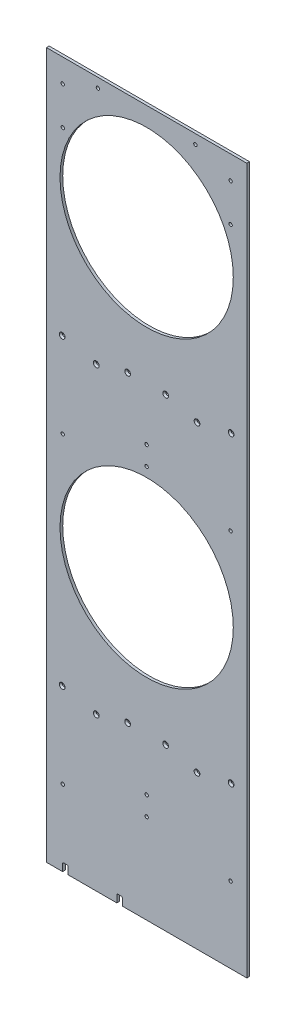
from build123d import *

# Parameters (mm, degrees)
SKETCH1_W                                     = 469.9
SKETCH1_H                                     = 2413
SKETCH1_R                                     = 203.2
BOSS_EXTRUDE1_DEPTH                           = 6.35
CSK_FOR_1_4_FLAT_HEAD_SOCKET_CAP_SCR_2_COUNT  = 2
CSK_FOR_1_4_FLAT_HEAD_SOCKET_CAP_SCR_2_PITCH  = 76.2
CSK_FOR_1_4_FLAT_HEAD_SOCKET_CAP_SCR_3_COUNT  = 2
CSK_FOR_1_4_FLAT_HEAD_SOCKET_CAP_SCR_3_PITCH  = 89.142542345
CSK_FOR_1_4_FLAT_HEAD_SOCKET_CAP_SCR_4_COUNT  = 2
CSK_FOR_1_4_FLAT_HEAD_SOCKET_CAP_SCR_4_PITCH  = 163.936718394
CSK_FOR_1_4_FLAT_HEAD_SOCKET_CAP_SCR_5_COUNT  = 2
CSK_FOR_1_4_FLAT_HEAD_SOCKET_CAP_SCR_5_PITCH  = 711.2
CSK_FOR_1_4_FLAT_HEAD_SOCKET_CAP_SCR_6_COUNT  = 2
CSK_FOR_1_4_FLAT_HEAD_SOCKET_CAP_SCR_6_PITCH  = 695.384275934
CSK_FOR_1_4_FLAT_HEAD_SOCKET_CAP_SCR_7_COUNT  = 2
CSK_FOR_1_4_FLAT_HEAD_SOCKET_CAP_SCR_7_PITCH  = 716.764837904
CSK_FOR_1_4_FLAT_HEAD_SOCKET_CAP_SCR_8_COUNT  = 2
CSK_FOR_1_4_FLAT_HEAD_SOCKET_CAP_SCR_8_PITCH  = 710.371803251
CSK_FOR_1_4_FLAT_HEAD_SOCKET_CAP_SCR_9_COUNT  = 2
CSK_FOR_1_4_FLAT_HEAD_SOCKET_CAP_SCR_9_PITCH  = 1422.4
CSK_FOR_1_4_FLAT_HEAD_SOCKET_CAP_SCR_10_COUNT = 2
CSK_FOR_1_4_FLAT_HEAD_SOCKET_CAP_SCR_10_PITCH = 1404.60778242
CSK_FOR_1_4_FLAT_HEAD_SOCKET_CAP_SCR_11_COUNT = 2
CSK_FOR_1_4_FLAT_HEAD_SOCKET_CAP_SCR_11_PITCH = 1425.190567207
CSK_FOR_1_4_FLAT_HEAD_SOCKET_CAP_SCR_12_COUNT = 2
CSK_FOR_1_4_FLAT_HEAD_SOCKET_CAP_SCR_12_PITCH = 1412.087755797
CSK_FOR_1_4_FLAT_HEAD_SOCKET_CAP_SCR_13_COUNT = 2
CSK_FOR_1_4_FLAT_HEAD_SOCKET_CAP_SCR_13_PITCH = 153.55813077
CSK_FOR_1_4_FLAT_HEAD_SOCKET_CAP_SCR_14_COUNT = 2
CSK_FOR_1_4_FLAT_HEAD_SOCKET_CAP_SCR_14_PITCH = 242.697219812
CSK_FOR_1_4_FLAT_HEAD_SOCKET_CAP_SCR_15_COUNT = 2
CSK_FOR_1_4_FLAT_HEAD_SOCKET_CAP_SCR_15_PITCH = 749.86024568
CSK_FOR_1_4_FLAT_HEAD_SOCKET_CAP_SCR_16_COUNT = 2
CSK_FOR_1_4_FLAT_HEAD_SOCKET_CAP_SCR_16_PITCH = 1441.280581843
CSK_FOR_1_4_FLAT_HEAD_SOCKET_CAP_SCR_17_COUNT = 2
CSK_FOR_1_4_FLAT_HEAD_SOCKET_CAP_SCR_17_PITCH = 1428.974413563
CSK_FOR_1_4_FLAT_HEAD_SOCKET_CAP_SCR_18_COUNT = 2
CSK_FOR_1_4_FLAT_HEAD_SOCKET_CAP_SCR_18_PITCH = 725.925992834
F_5_16_0_3125_DIAMETER_HOLE1_D                = 7.9375
SKETCH6_W                                     = 469.9
SKETCH6_H                                     = 758.19
CUT_EXTRUDE1_DEPTH                            = 7.35
SKETCH8_W                                     = 13.208
SKETCH8_H                                     = 19.05
CUT_EXTRUDE2_DEPTH                            = 7.35
FILLET1_R                                     = 3.175


with BuildPart() as part:
    # Sketch1 → Boss-Extrude1 (new body)
    with BuildSketch(Plane.XY):
        with Locations((0, 1206.5)):
            Rectangle(SKETCH1_W, SKETCH1_H)
        with Locations((0, 695.96)):
            Circle(SKETCH1_R, mode=Mode.SUBTRACT)
        with Locations((0, 1407.16)):
            Circle(SKETCH1_R, mode=Mode.SUBTRACT)
        with Locations((0, 2118.36)):
            Circle(SKETCH1_R, mode=Mode.SUBTRACT)
    extrude(amount=BOSS_EXTRUDE1_DEPTH)

    # Sketch3 → CSK for 1/4 Flat Head Socket Cap Screw1 (revolve, cut)
    with BuildSketch(Plane(origin=(44.571271172, 378.545152647, 6.35), x_dir=(0, -1, 0), z_dir=(1, 0, 0))):
        Polygon((0, 0), (0, 6.35), (3.3782, 6.35), (3.3782, 3.871564875), (6.7437, 0), align=None)
    csk_for_1_4_flat_head_socket_cap_screw1 = revolve(axis=Axis((44.571271172, 378.545152647, 12.7), (0, 0, -1)), mode=Mode.SUBTRACT)

    # CSK for 1_4 Flat Head Socket Cap Scr 2: CSK for 1/4 Flat Head Socket Cap Screw1 ×2
    with Locations(*[Vector(0.965925826, -0.258819045, 0) * (i * CSK_FOR_1_4_FLAT_HEAD_SOCKET_CAP_SCR_2_PITCH) for i in range(1, CSK_FOR_1_4_FLAT_HEAD_SOCKET_CAP_SCR_2_COUNT)]):
        add(csk_for_1_4_flat_head_socket_cap_screw1, mode=Mode.SUBTRACT)

    # CSK for 1_4 Flat Head Socket Cap Scr 3: CSK for 1/4 Flat Head Socket Cap Screw1 ×2
    with Locations(*[(-i * CSK_FOR_1_4_FLAT_HEAD_SOCKET_CAP_SCR_3_PITCH, 0, 0) for i in range(1, CSK_FOR_1_4_FLAT_HEAD_SOCKET_CAP_SCR_3_COUNT)]):
        add(csk_for_1_4_flat_head_socket_cap_screw1, mode=Mode.SUBTRACT)

    # CSK for 1_4 Flat Head Socket Cap Scr 4: CSK for 1/4 Flat Head Socket Cap Screw1 ×2
    with Locations(*[Vector(-0.99273727, -0.120302586, 0) * (i * CSK_FOR_1_4_FLAT_HEAD_SOCKET_CAP_SCR_4_PITCH) for i in range(1, CSK_FOR_1_4_FLAT_HEAD_SOCKET_CAP_SCR_4_COUNT)]):
        add(csk_for_1_4_flat_head_socket_cap_screw1, mode=Mode.SUBTRACT)

    # CSK for 1_4 Flat Head Socket Cap Scr 5: CSK for 1/4 Flat Head Socket Cap Screw1 ×2
    with Locations(*[(0, i * CSK_FOR_1_4_FLAT_HEAD_SOCKET_CAP_SCR_5_PITCH, 0) for i in range(1, CSK_FOR_1_4_FLAT_HEAD_SOCKET_CAP_SCR_5_COUNT)]):
        add(csk_for_1_4_flat_head_socket_cap_screw1, mode=Mode.SUBTRACT)

    # CSK for 1_4 Flat Head Socket Cap Scr 6: CSK for 1/4 Flat Head Socket Cap Screw1 ×2
    with Locations(*[Vector(0.105845862, 0.994382549, 0) * (i * CSK_FOR_1_4_FLAT_HEAD_SOCKET_CAP_SCR_6_PITCH) for i in range(1, CSK_FOR_1_4_FLAT_HEAD_SOCKET_CAP_SCR_6_COUNT)]):
        add(csk_for_1_4_flat_head_socket_cap_screw1, mode=Mode.SUBTRACT)

    # CSK for 1_4 Flat Head Socket Cap Scr 7: CSK for 1/4 Flat Head Socket Cap Screw1 ×2
    with Locations(*[Vector(-0.124367907, 0.992236173, 0) * (i * CSK_FOR_1_4_FLAT_HEAD_SOCKET_CAP_SCR_7_PITCH) for i in range(1, CSK_FOR_1_4_FLAT_HEAD_SOCKET_CAP_SCR_7_COUNT)]):
        add(csk_for_1_4_flat_head_socket_cap_screw1, mode=Mode.SUBTRACT)

    # CSK for 1_4 Flat Head Socket Cap Scr 8: CSK for 1/4 Flat Head Socket Cap Screw1 ×2
    with Locations(*[Vector(-0.229099874, 0.973402922, 0) * (i * CSK_FOR_1_4_FLAT_HEAD_SOCKET_CAP_SCR_8_PITCH) for i in range(1, CSK_FOR_1_4_FLAT_HEAD_SOCKET_CAP_SCR_8_COUNT)]):
        add(csk_for_1_4_flat_head_socket_cap_screw1, mode=Mode.SUBTRACT)

    # CSK for 1_4 Flat Head Socket Cap Scr 9: CSK for 1/4 Flat Head Socket Cap Screw1 ×2
    with Locations(*[(0, i * CSK_FOR_1_4_FLAT_HEAD_SOCKET_CAP_SCR_9_PITCH, 0) for i in range(1, CSK_FOR_1_4_FLAT_HEAD_SOCKET_CAP_SCR_9_COUNT)]):
        add(csk_for_1_4_flat_head_socket_cap_screw1, mode=Mode.SUBTRACT)

    # CSK for 1_4 Flat Head Socket Cap Scr 10: CSK for 1/4 Flat Head Socket Cap Screw1 ×2
    with Locations(*[Vector(0.052401495, 0.998626098, 0) * (i * CSK_FOR_1_4_FLAT_HEAD_SOCKET_CAP_SCR_10_PITCH) for i in range(1, CSK_FOR_1_4_FLAT_HEAD_SOCKET_CAP_SCR_10_COUNT)]):
        add(csk_for_1_4_flat_head_socket_cap_screw1, mode=Mode.SUBTRACT)

    # CSK for 1_4 Flat Head Socket Cap Scr 11: CSK for 1/4 Flat Head Socket Cap Screw1 ×2
    with Locations(*[Vector(-0.062547805, 0.998041969, 0) * (i * CSK_FOR_1_4_FLAT_HEAD_SOCKET_CAP_SCR_11_PITCH) for i in range(1, CSK_FOR_1_4_FLAT_HEAD_SOCKET_CAP_SCR_11_COUNT)]):
        add(csk_for_1_4_flat_head_socket_cap_screw1, mode=Mode.SUBTRACT)

    # CSK for 1_4 Flat Head Socket Cap Scr 12: CSK for 1/4 Flat Head Socket Cap Screw1 ×2
    with Locations(*[Vector(-0.115252108, 0.993336273, 0) * (i * CSK_FOR_1_4_FLAT_HEAD_SOCKET_CAP_SCR_12_PITCH) for i in range(1, CSK_FOR_1_4_FLAT_HEAD_SOCKET_CAP_SCR_12_COUNT)]):
        add(csk_for_1_4_flat_head_socket_cap_screw1, mode=Mode.SUBTRACT)

    # CSK for 1_4 Flat Head Socket Cap Scr 13: CSK for 1/4 Flat Head Socket Cap Screw1 ×2
    with Locations(*[Vector(0.999938773, -0.011065747, 0) * (i * CSK_FOR_1_4_FLAT_HEAD_SOCKET_CAP_SCR_13_PITCH) for i in range(1, CSK_FOR_1_4_FLAT_HEAD_SOCKET_CAP_SCR_13_COUNT)]):
        add(csk_for_1_4_flat_head_socket_cap_screw1, mode=Mode.SUBTRACT)

    # CSK for 1_4 Flat Head Socket Cap Scr 14: CSK for 1/4 Flat Head Socket Cap Screw1 ×2
    with Locations(*[Vector(-0.999975489, -0.007001462, 0) * (i * CSK_FOR_1_4_FLAT_HEAD_SOCKET_CAP_SCR_14_PITCH) for i in range(1, CSK_FOR_1_4_FLAT_HEAD_SOCKET_CAP_SCR_14_COUNT)]):
        add(csk_for_1_4_flat_head_socket_cap_screw1, mode=Mode.SUBTRACT)

    # CSK for 1_4 Flat Head Socket Cap Scr 15: CSK for 1/4 Flat Head Socket Cap Screw1 ×2
    with Locations(*[Vector(-0.32364867, 0.946177329, 0) * (i * CSK_FOR_1_4_FLAT_HEAD_SOCKET_CAP_SCR_15_PITCH) for i in range(1, CSK_FOR_1_4_FLAT_HEAD_SOCKET_CAP_SCR_15_COUNT)]):
        add(csk_for_1_4_flat_head_socket_cap_screw1, mode=Mode.SUBTRACT)

    # CSK for 1_4 Flat Head Socket Cap Scr 16: CSK for 1/4 Flat Head Socket Cap Screw1 ×2
    with Locations(*[Vector(-0.168385861, 0.985721158, 0) * (i * CSK_FOR_1_4_FLAT_HEAD_SOCKET_CAP_SCR_16_PITCH) for i in range(1, CSK_FOR_1_4_FLAT_HEAD_SOCKET_CAP_SCR_16_COUNT)]):
        add(csk_for_1_4_flat_head_socket_cap_screw1, mode=Mode.SUBTRACT)

    # CSK for 1_4 Flat Head Socket Cap Scr 17: CSK for 1/4 Flat Head Socket Cap Screw1 ×2
    with Locations(*[Vector(0.107453799, 0.994210079, 0) * (i * CSK_FOR_1_4_FLAT_HEAD_SOCKET_CAP_SCR_17_PITCH) for i in range(1, CSK_FOR_1_4_FLAT_HEAD_SOCKET_CAP_SCR_17_COUNT)]):
        add(csk_for_1_4_flat_head_socket_cap_screw1, mode=Mode.SUBTRACT)

    # CSK for 1_4 Flat Head Socket Cap Scr 18: CSK for 1/4 Flat Head Socket Cap Screw1 ×2
    with Locations(*[Vector(0.211521189, 0.977373412, 0) * (i * CSK_FOR_1_4_FLAT_HEAD_SOCKET_CAP_SCR_18_PITCH) for i in range(1, CSK_FOR_1_4_FLAT_HEAD_SOCKET_CAP_SCR_18_COUNT)]):
        add(csk_for_1_4_flat_head_socket_cap_screw1, mode=Mode.SUBTRACT)

    # 5/16 (0.3125) Diameter Hole1 (through all)
    with Locations(Plane.XY.offset(6.35)):
        with Locations((0, 254.635), (0, 210.185), (-196.85, 177.8), (196.85, 177.8), (0, 965.835), (0, 921.385), (-196.85, 889), (196.85, 889), (-196.85, 1600.2), (196.85, 1600.2), (-114.3, 1632.585), (-114.3, 1677.035), (114.3, 1677.035), (114.3, 1632.585), (196.85, 1511.3), (-196.85, 1511.3)):
            Hole(F_5_16_0_3125_DIAMETER_HOLE1_D / 2)

    # Sketch6 → Cut-Extrude1 (cut, through all)
    with BuildSketch(Plane.XY.offset(6.35)):
        with Locations((0, 2033.905)):
            Rectangle(SKETCH6_W, SKETCH6_H)
    extrude(amount=-CUT_EXTRUDE1_DEPTH, mode=Mode.SUBTRACT)

    # Sketch8 → Cut-Extrude2 (cut, through all)
    with BuildSketch(Plane.XY.offset(6.35)):
        with Locations((-63.5, 9.525)):
            Rectangle(SKETCH8_W, SKETCH8_H)
        with Locations((-190.5, 9.525)):
            Rectangle(SKETCH8_W, SKETCH8_H)
    extrude(amount=-CUT_EXTRUDE2_DEPTH, mode=Mode.SUBTRACT)

    # Fillet1
    fillet1_edges = [part.edges().sort_by_distance(p)[0] for p in [
        (-70.104, 19.05, 3.175),
        (-56.896, 19.05, 3.175),
        (-197.104, 19.05, 3.175),
        (-183.896, 19.05, 3.175),
    ]]
    fillet(fillet1_edges, radius=FILLET1_R)


solid = part.part
